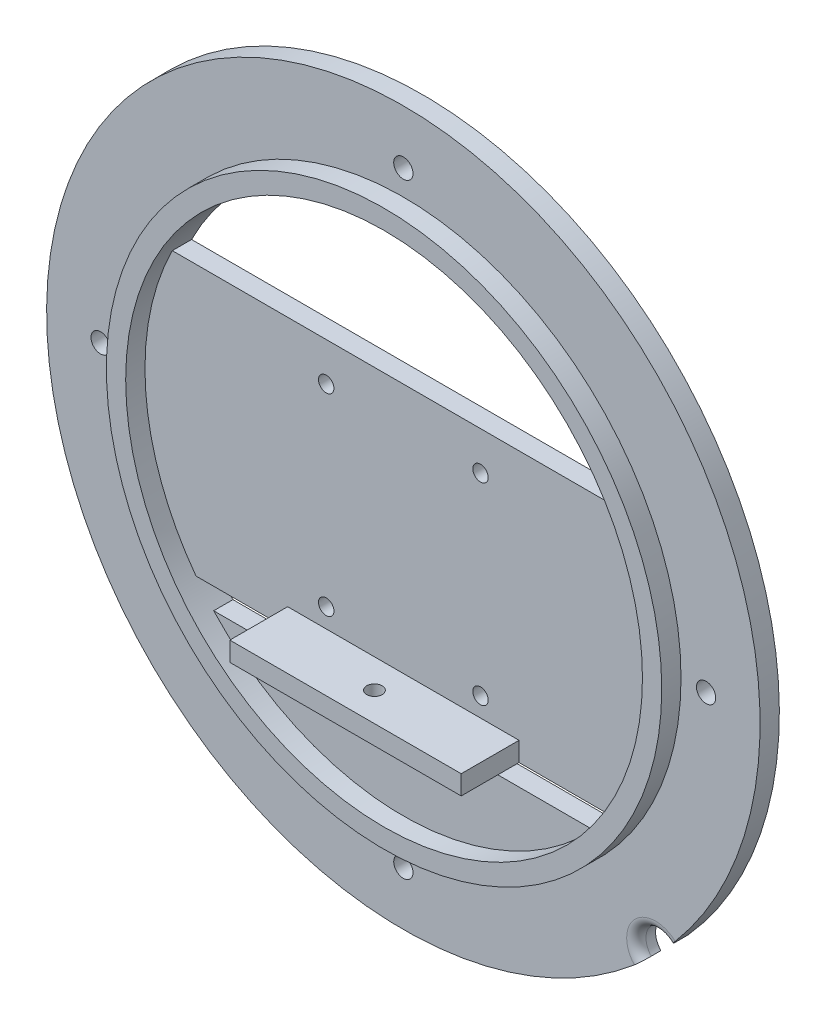
from build123d import *

# Parameters (mm, degrees)
SKETCH1_R           = 92.5
BOSS_EXTRUDE1_DEPTH = 5
SKETCH2_R           = 72
BOSS_EXTRUDE2_DEPTH = 5
SKETCH3_R           = 67
CUT_EXTRUDE1_DEPTH  = 11
SKETCH4_W           = 140
SKETCH4_H           = 70
BOSS_EXTRUDE3_DEPTH = 5
FILLET1_R           = 2.5
SKETCH7_W           = 110
SKETCH7_H           = 25
BOSS_EXTRUDE5_DEPTH = 5
SKETCH11_R          = 2
CUT_EXTRUDE4_DEPTH  = 5
SKETCH12_R          = 2.5
CUT_EXTRUDE5_DEPTH  = 5
SKETCH6_W           = 60
SKETCH6_H           = 5
BOSS_EXTRUDE6_DEPTH = 15
SKETCH13_R          = 2
CUT_EXTRUDE6_DEPTH  = 5
SKETCH14_R          = 5
CUT_EXTRUDE7_DEPTH  = 10
FILLET2_R           = 2.5


with BuildPart() as part:
    # Sketch1 → Boss-Extrude1 (new body)
    with BuildSketch(Plane.XY):
        Circle(SKETCH1_R)
    extrude(amount=BOSS_EXTRUDE1_DEPTH)

    # Sketch2 → Boss-Extrude2 (add)
    with BuildSketch(Plane.XY.offset(5)):
        Circle(SKETCH2_R)
    extrude(amount=BOSS_EXTRUDE2_DEPTH)

    # Sketch3 → Cut-Extrude1 (cut, through all)
    with BuildSketch(Plane(origin=(0, 0, 0), x_dir=(-1, 0, 0), z_dir=(0, 0, -1))):
        Circle(SKETCH3_R)
    extrude(amount=-CUT_EXTRUDE1_DEPTH, mode=Mode.SUBTRACT)

    # Sketch4 → Boss-Extrude3 (add)
    with BuildSketch(Plane(origin=(0, 0, 0), x_dir=(-1, 0, 0), z_dir=(0, 0, -1))):
        with Locations((0, -5)):
            Rectangle(SKETCH4_W, SKETCH4_H)
    extrude(amount=-BOSS_EXTRUDE3_DEPTH)

    # Fillet1
    fillet1_edges = [part.edges().sort_by_distance(p)[0] for p in [
        (0, -40, 0),
    ]]
    fillet(fillet1_edges, radius=FILLET1_R)

    # Sketch7 → Boss-Extrude5 (add)
    with BuildSketch(Plane(origin=(0, 0, 0), x_dir=(-1, 0, 0), z_dir=(0, 0, -1))):
        with Locations((0, -58)):
            Rectangle(SKETCH7_W, SKETCH7_H)
    extrude(amount=-BOSS_EXTRUDE5_DEPTH)

    # Sketch11 → Cut-Extrude4 (cut)
    with BuildSketch(Plane(origin=(0, 0, 0), x_dir=(-1, 0, 0), z_dir=(0, 0, -1))):
        with Locations((-20, -30)):
            Circle(SKETCH11_R)
        with Locations((-20, 20)):
            Circle(SKETCH11_R)
        with Locations((20, 20)):
            Circle(SKETCH11_R)
        with Locations((20, -30)):
            Circle(SKETCH11_R)
    extrude(amount=-CUT_EXTRUDE4_DEPTH, mode=Mode.SUBTRACT)

    # Sketch12 → Cut-Extrude5 (cut)
    with BuildSketch(Plane(origin=(0, 0, 0), x_dir=(-1, 0, 0), z_dir=(0, 0, -1))):
        with Locations((0, -78.5)):
            Circle(SKETCH12_R)
        with Locations((-78.5, 0)):
            Circle(SKETCH12_R)
        with Locations((0, 78.5)):
            Circle(SKETCH12_R)
        with Locations((78.5, 0)):
            Circle(SKETCH12_R)
    extrude(amount=-CUT_EXTRUDE5_DEPTH, mode=Mode.SUBTRACT)

    # Sketch6 → Boss-Extrude6 (add)
    with BuildSketch(Plane.XY.offset(5)):
        with Locations((0, -37.5)):
            Rectangle(SKETCH6_W, SKETCH6_H)
    extrude(amount=BOSS_EXTRUDE6_DEPTH)

    # Sketch13 → Cut-Extrude6 (cut)
    with BuildSketch(Plane.XZ.offset(40)):
        with Locations((0, 12.5)):
            Circle(SKETCH13_R)
    extrude(amount=-CUT_EXTRUDE6_DEPTH, mode=Mode.SUBTRACT)

    # Sketch14 → Cut-Extrude7 (cut)
    with BuildSketch(Plane(origin=(0, 0, 0), x_dir=(-1, 0, 0), z_dir=(0, 0, -1))):
        with Locations((-65.40737726, -65.40737726)):
            Circle(SKETCH14_R)
    extrude(amount=-CUT_EXTRUDE7_DEPTH, mode=Mode.SUBTRACT)

    # Fillet2
    fillet2_edges = [part.edges().sort_by_distance(p)[0] for p in [
        (61.871843354, -61.871843354, 5),
    ]]
    fillet(fillet2_edges, radius=FILLET2_R)


solid = part.part
